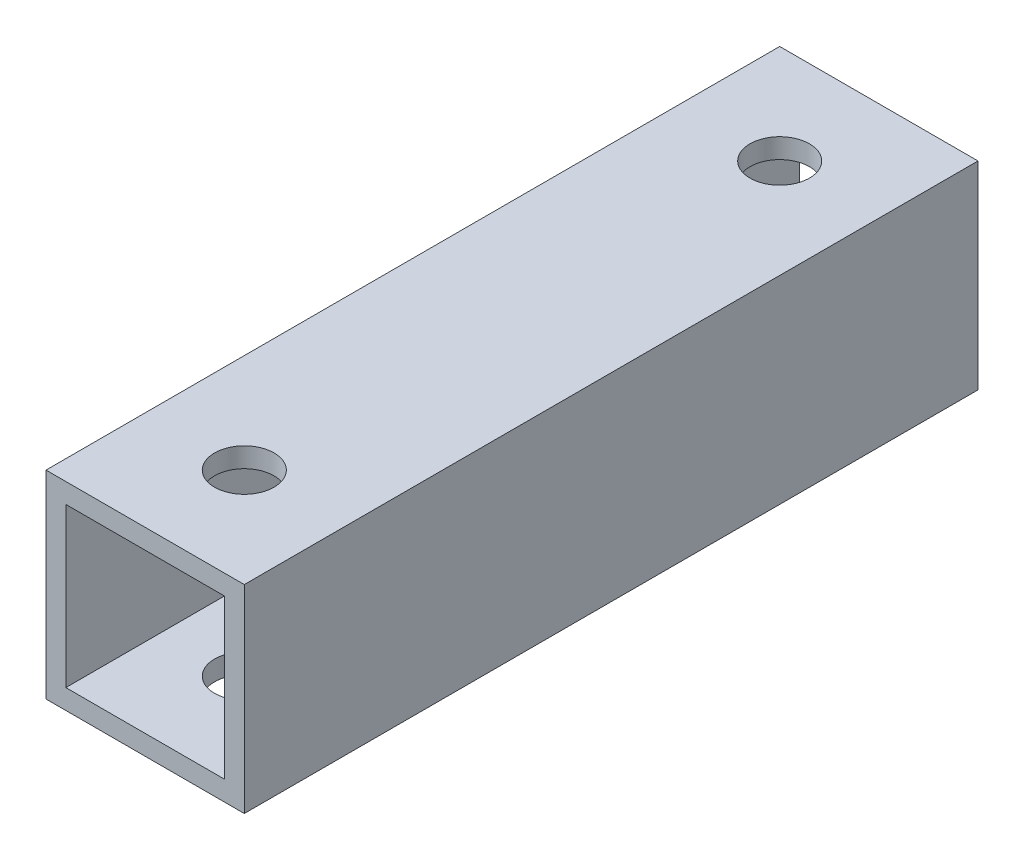
from build123d import *

# Parameters (mm, degrees)
SKETCH_1_W          = 10
SKETCH_1_H          = 10
SKETCH_1_W_2        = 8
SKETCH_1_H_2        = 8
EXTRUDE_1_DEPTH     = 37
SKETCH_2_R          = 1.5
CUT_EXTRUDE_1_DEPTH = 10


with BuildPart() as part:
    # 草图1 → 拉伸-薄壁1 (new body)
    with BuildSketch(Plane.XY):
        with Locations((12.317764791, -104.586504738)):
            Rectangle(SKETCH_1_W, SKETCH_1_H)
        with Locations((12.317764791, -104.586504738)):
            Rectangle(SKETCH_1_W_2, SKETCH_1_H_2, mode=Mode.SUBTRACT)
    extrude(amount=EXTRUDE_1_DEPTH)

    # 草图2 → 切除-拉伸1 (cut)
    with BuildSketch(Plane.XZ.offset(109.586504738)):
        with Locations((12.317764791, 5)):
            Circle(SKETCH_2_R)
        with Locations((12.317764791, 32)):
            Circle(SKETCH_2_R)
    extrude(amount=-CUT_EXTRUDE_1_DEPTH, mode=Mode.SUBTRACT)


solid = part.part
